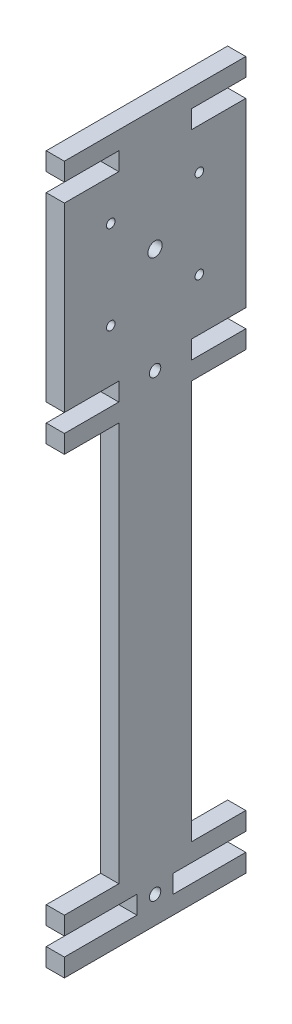
from build123d import *

# Parameters (mm, degrees)
SKETCH1_R           = 2
BOSS_EXTRUDE1_DEPTH = 6.35
SKETCH3_W           = 19.05
SKETCH3_H           = 139.7
CUT_EXTRUDE2_DEPTH  = 6.35
SKETCH2_R           = 1.500000048
SKETCH2_R_2         = 2.5
CUT_EXTRUDE3_DEPTH  = 6.35
SKETCH4_W           = 6.35
SKETCH4_H           = 6.35
CUT_EXTRUDE4_DEPTH  = 6.35
SKETCH5_W           = 19.05
SKETCH5_H           = 6.35
CUT_EXTRUDE5_DEPTH  = 6.35


with BuildPart() as part:
    # Sketch1 → Boss-Extrude1 (new body)
    with BuildSketch(Plane(origin=(0, 0, 0), x_dir=(0, 0, -1), z_dir=(1, 0, 0))):
        Polygon((63.5, 184.15), (63.5, 215.9), (63.5, 228.6), (63.5, 254), (63.5, 260.35), (0, 260.35), (0, 254), (0, 228.6), (0, 215.9), (0, 184.15), (19.05, 184.15), (19.05, 177.8), (0, 177.8), (0, 25.4), (19.05, 25.4), (19.05, 19.05), (0, 19.05), (0, 12.7), (61.867851021, 12.7), (63.5, 12.7), (63.5, 19.05), (57.15, 19.05), (44.45, 19.05), (44.45, 25.4), (57.15, 25.4), (63.5, 25.4), (63.5, 177.8), (44.45, 177.8), (44.45, 184.15), align=None)
        with Locations((31.75, 180.975)):
            Circle(SKETCH1_R, mode=Mode.SUBTRACT)
        with Locations((31.75, 22.225)):
            Circle(SKETCH1_R, mode=Mode.SUBTRACT)
    extrude(amount=BOSS_EXTRUDE1_DEPTH)

    # Sketch3 → Cut-Extrude2 (cut)
    with BuildSketch(Plane(origin=(6.35, 0, 0), x_dir=(0, 0, -1), z_dir=(1, 0, 0))):
        with Locations((9.525, 101.6)):
            Rectangle(SKETCH3_W, SKETCH3_H)
        with Locations((53.975, 101.6)):
            Rectangle(SKETCH3_W, SKETCH3_H)
    extrude(amount=-CUT_EXTRUDE2_DEPTH, mode=Mode.SUBTRACT)

    # Sketch2 → Cut-Extrude3 (cut)
    with BuildSketch(Plane(origin=(6.35, 0, 0), x_dir=(0, 0, -1), z_dir=(1, 0, 0))):
        with Locations((47.250000115, 233.350000152)):
            Circle(SKETCH2_R)
        with Locations((31.75, 217.850000037)):
            Circle(SKETCH2_R_2)
        with Locations((47.250000115, 202.349999922)):
            Circle(SKETCH2_R)
        with Locations((16.249999885, 202.349999922)):
            Circle(SKETCH2_R)
        with Locations((16.249999885, 233.350000152)):
            Circle(SKETCH2_R)
    extrude(amount=-CUT_EXTRUDE3_DEPTH, mode=Mode.SUBTRACT)

    # Sketch4 → Cut-Extrude4 (cut)
    with BuildSketch(Plane(origin=(6.35, 0, 0), x_dir=(0, 0, -1), z_dir=(1, 0, 0))):
        with Locations((22.225, 22.225)):
            Rectangle(SKETCH4_W, SKETCH4_H)
        with Locations((41.275, 22.225)):
            Rectangle(SKETCH4_W, SKETCH4_H)
    extrude(amount=-CUT_EXTRUDE4_DEPTH, mode=Mode.SUBTRACT)

    # Sketch5 → Cut-Extrude5 (cut)
    with BuildSketch(Plane(origin=(6.35, 0, 0), x_dir=(0, 0, -1), z_dir=(1, 0, 0))):
        with Locations((9.525, 250.825)):
            Rectangle(SKETCH5_W, SKETCH5_H)
        with Locations((53.975, 250.825)):
            Rectangle(SKETCH5_W, SKETCH5_H)
    extrude(amount=-CUT_EXTRUDE5_DEPTH, mode=Mode.SUBTRACT)


solid = part.part
